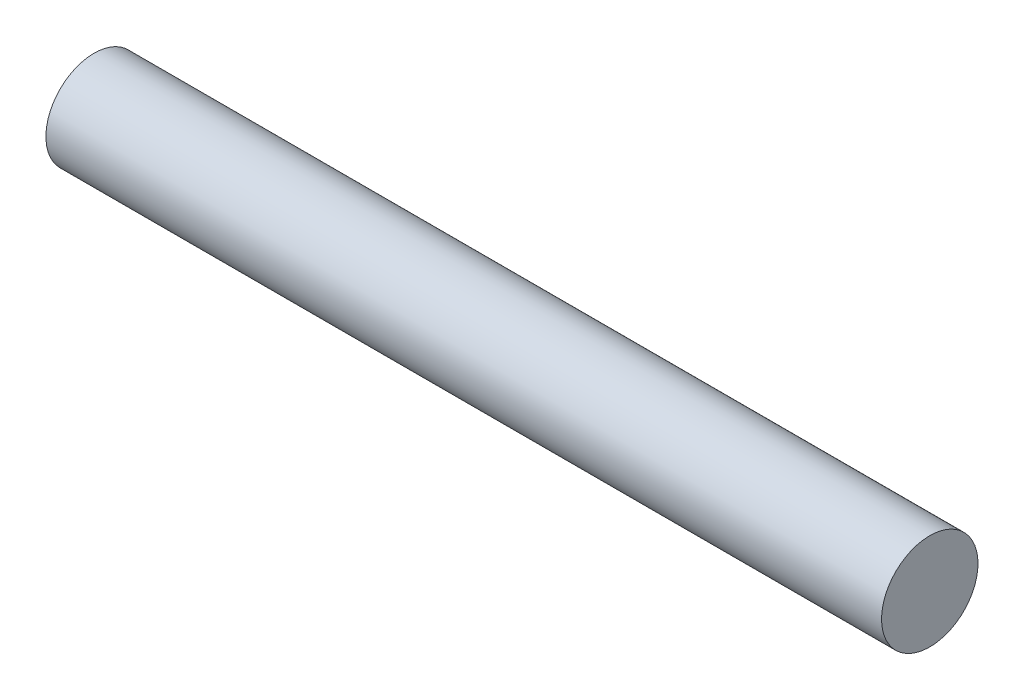
from build123d import *

# Parameters (mm, degrees)
CROQUIS2_R = 9.525


with BuildPart() as part:
    # Barrer1: sweep along a path in Croquis1
    with BuildLine(Plane.XY) as barrer1_path:
        Line((0, 0), (165.1, 0))
    # Croquis2 → Barrer1 (sweep)
    with BuildSketch(Plane(origin=(0, 0, 0), x_dir=(0, 0, -1), z_dir=(1, 0, 0))):
        Circle(CROQUIS2_R)
    sweep(path=barrer1_path.line)


solid = part.part
